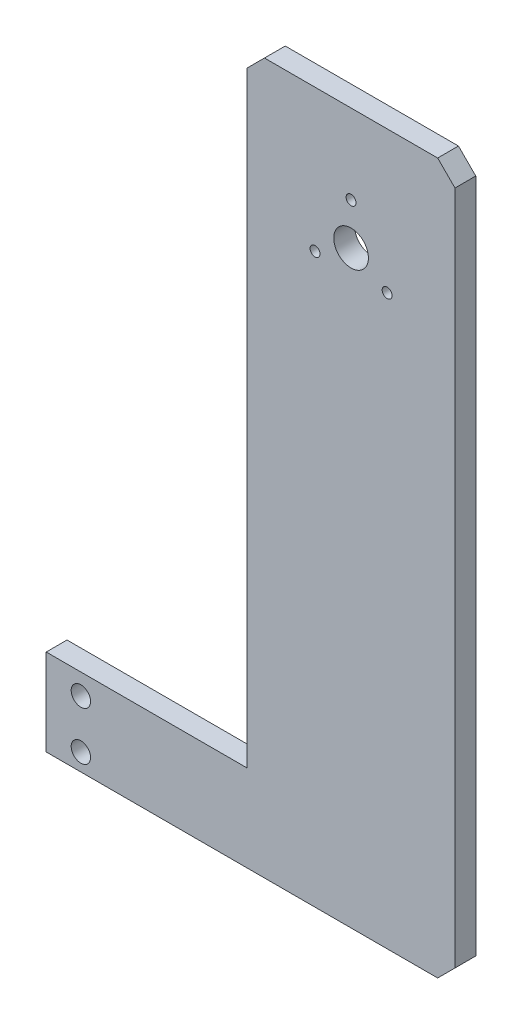
from build123d import *

# Parameters (mm, degrees)
BOSS_EXTRUDE1_DEPTH = 6
SKETCH2_R           = 2.8
SKETCH2_R_2         = 5
SKETCH2_R_3         = 1.43
CUT_EXTRUDE1_DEPTH  = 7


with BuildPart() as part:
    # Sketch1 → Boss-Extrude1 (new body)
    with BuildSketch(Plane.XY):
        Polygon((0, 200), (0, 5), (-5, 0), (-118, 0), (-118, 25), (-60, 25), (-60, 200), (-55, 205), (-5, 205), align=None)
    extrude(amount=BOSS_EXTRUDE1_DEPTH)

    # Sketch2 → Cut-Extrude1 (cut, through all)
    with BuildSketch(Plane.XY.offset(6)):
        with Locations((-108, 19)):
            Circle(SKETCH2_R)
        with Locations((-108, 5)):
            Circle(SKETCH2_R)
        with Locations((-30, 170)):
            Circle(SKETCH2_R_2)
        with Locations((-19.6, 163.9955572)):
            Circle(SKETCH2_R_3)
        with Locations((-40.4, 163.9955572)):
            Circle(SKETCH2_R_3)
        with Locations((-30, 182.008885599)):
            Circle(SKETCH2_R_3)
    extrude(amount=-CUT_EXTRUDE1_DEPTH, mode=Mode.SUBTRACT)


solid = part.part
